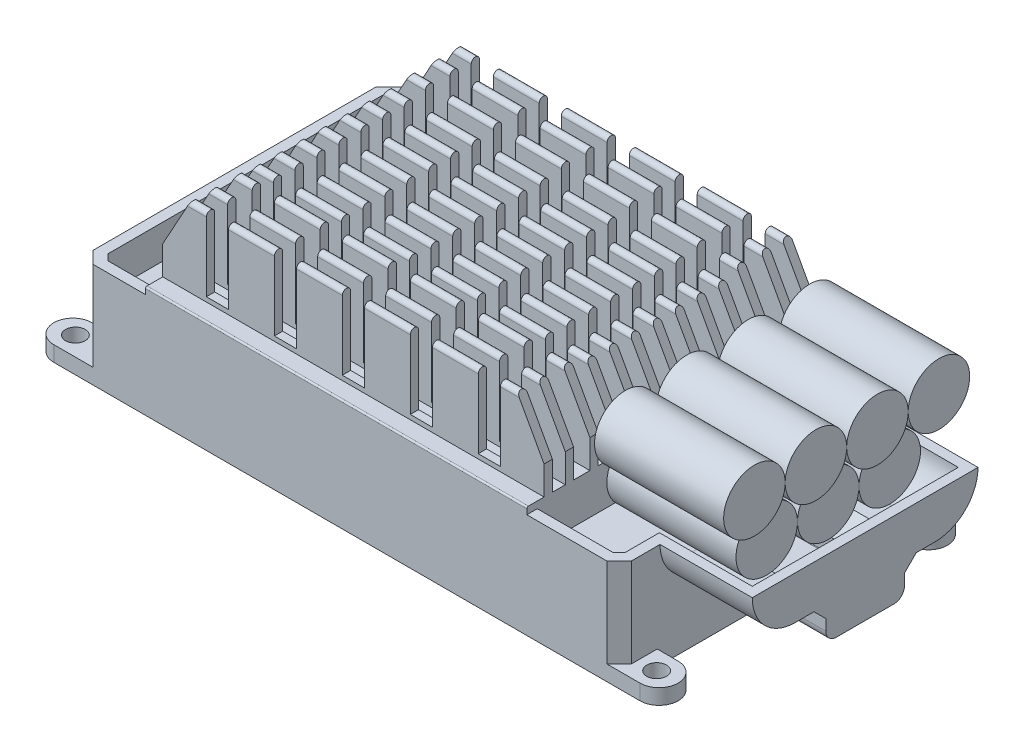
from build123d import *

# Parameters (mm, degrees)
SKETCH1_W               = 87.5
SKETCH1_H               = 50
BOSS_EXTRUDE1_DEPTH     = 17
SKETCH2_R               = 1.6
BOSS_EXTRUDE2_DEPTH     = 2.5
CHAMFER1_SIZE           = 2
BOSS_EXTRUDE3_DEPTH     = 62
SKETCH4_W               = 3.6
SKETCH4_H               = 11.9
CUT_EXTRUDE1_DEPTH      = 3.8
CUT_EXTRUDE1_DEPTH_BACK = 48.2
BOSS_EXTRUDE4_DEPTH     = 15
CUT_EXTRUDE3_DEPTH      = 5.5
CUT_EXTRUDE2_START      = -1.6
CUT_EXTRUDE2_DEPTH      = 15.1
BOSS_EXTRUDE5_START     = -3
SKETCH6_R               = 5
BOSS_EXTRUDE5_DEPTH     = 21
LPATTERN1_COUNT         = 4
LPATTERN1_PITCH         = 10
BOSS_EXTRUDE6_START     = -6
SKETCH7_R               = 4.9995
BOSS_EXTRUDE6_DEPTH     = 21
BOSS_EXTRUDE6_2_DEPTH   = 21
BOSS_EXTRUDE6_3_DEPTH   = 21


with BuildPart() as part:
    # Sketch1 → Boss-Extrude1 (new body)
    with BuildSketch(Plane(origin=(0, 0, 0), x_dir=(1, 0, 0), z_dir=(0, 1, 0))):
        Rectangle(SKETCH1_W, SKETCH1_H)
    extrude(amount=BOSS_EXTRUDE1_DEPTH)

    # Sketch2 → Boss-Extrude2 (add)
    with BuildSketch(Plane.XZ):
        with BuildLine():
            Line((43.75, 25), (47.15, 25))
            ThreePointArc((47.15, 25), (50.25, 21.9), (47.15, 18.8))
            Line((47.15, 18.8), (43.75, 18.8))
            Line((43.75, 18.8), (43.75, 25))
        make_face()
        with Locations((46.75, 21.9)):
            Circle(SKETCH2_R, mode=Mode.SUBTRACT)
        with BuildLine():
            Line((-43.75, 25), (-48.15, 25))
            ThreePointArc((-48.15, 25), (-51.25, 21.9), (-48.15, 18.8))
            Line((-48.15, 18.8), (-43.75, 18.8))
            Line((-43.75, 18.8), (-43.75, 25))
        make_face()
        with Locations((-47.75, 21.9)):
            Circle(SKETCH2_R, mode=Mode.SUBTRACT)
    boss_extrude2 = extrude(amount=-BOSS_EXTRUDE2_DEPTH)

    # Mirror5: Boss-Extrude2 across plane
    add(boss_extrude2.mirror(Plane.XY))

    # Chamfer1
    chamfer1_edges = [part.edges().sort_by_distance(p)[0] for p in [
        (-43.75, 9.75, 25),
        (-43.75, 9.75, -25),
        (43.75, 9.75, -25),
        (43.75, 9.75, 25),
    ]]
    chamfer(chamfer1_edges, length=CHAMFER1_SIZE)

    # Sketch3 → Boss-Extrude3 (add)
    with BuildSketch(Plane.ZY.offset(33.25)):
        with BuildLine():
            Line((-25, 17), (0, 17))
            Line((0, 17), (0, 30.1))
            ThreePointArc((0, 30.1), (-0.477297077, 29.902297077), (-0.675, 29.425))
            Line((-0.675, 29.425), (-0.675, 18.1))
            Line((-0.675, 18.1), (-2.9, 18.1))
            Line((-2.9, 18.1), (-2.9, 29.425))
            ThreePointArc((-2.9, 29.425), (-3.575, 30.1), (-4.25, 29.425))
            Line((-4.25, 29.425), (-4.25, 18.1))
            Line((-4.25, 18.1), (-6.45, 18.1))
            Line((-6.45, 18.1), (-6.45, 29.425))
            ThreePointArc((-6.45, 29.425), (-7.125, 30.1), (-7.8, 29.425))
            Line((-7.8, 29.425), (-7.8, 18.1))
            Line((-7.8, 18.1), (-9.95, 18.1))
            Line((-9.95, 18.1), (-9.95, 29.425))
            ThreePointArc((-9.95, 29.425), (-10.625, 30.1), (-11.3, 29.425))
            Line((-11.3, 29.425), (-11.3, 18.1))
            Line((-11.3, 18.1), (-13.4, 18.1))
            Line((-13.4, 18.1), (-13.4, 30.075))
            ThreePointArc((-13.4, 30.075), (-14.075, 30.75), (-14.75, 30.075))
            Line((-14.75, 30.075), (-14.75, 18.1))
            Line((-14.75, 18.1), (-17.4, 18.1))
            Line((-17.4, 18.1), (-17.4, 30.075))
            ThreePointArc((-17.4, 30.075), (-18.075, 30.75), (-18.75, 30.075))
            Line((-18.75, 30.075), (-18.75, 18.1))
            Line((-18.75, 18.1), (-20.85, 18.1))
            Line((-20.85, 18.1), (-20.85, 30.075))
            ThreePointArc((-20.85, 30.075), (-21.525, 30.75), (-22.2, 30.075))
            Line((-22.2, 30.075), (-22.2, 18.1))
            Line((-22.2, 18.1), (-24.75, 18.1))
            ThreePointArc((-24.75, 18.1), (-24.926776695, 18.026776695), (-25, 17.85))
            Line((-25, 17.85), (-25, 17))
        make_face()
    boss_extrude3 = extrude(amount=-BOSS_EXTRUDE3_DEPTH)

    # Mirror3: Boss-Extrude3 across plane
    add(boss_extrude3.mirror(Plane.XY))

    # Sketch4 → Cut-Extrude1 (cut, two sides)
    with BuildSketch(Plane(origin=(0, 0, -22.2), x_dir=(-1, 0, 0), z_dir=(0, 0, -1))) as cut_extrude1_sk:
        Polygon((28.85, 30.75), (33.25, 22.75), (33.25, 30.75), align=None)
        Polygon((-28.75, 22.75), (-24.35, 30.75), (-28.75, 30.75), align=None)
        with Locations((-19.85, 24.8)):
            Rectangle(SKETCH4_W, SKETCH4_H)
        with Locations((-8.8, 24.8)):
            Rectangle(SKETCH4_W, SKETCH4_H)
        with Locations((2.25, 24.8)):
            Rectangle(SKETCH4_W, SKETCH4_H)
        with Locations((13.3, 24.8)):
            Rectangle(SKETCH4_W, SKETCH4_H)
        with Locations((24.35, 24.8)):
            Rectangle(SKETCH4_W, SKETCH4_H)
    extrude(amount=CUT_EXTRUDE1_DEPTH, mode=Mode.SUBTRACT)
    extrude(cut_extrude1_sk.sketch, amount=-CUT_EXTRUDE1_DEPTH_BACK, mode=Mode.SUBTRACT)

    # Sketch5 → Boss-Extrude4 (add)
    with BuildSketch(Plane(origin=(43.75, 0, 0), x_dir=(0, 0, -1), z_dir=(1, 0, 0))):
        with BuildLine():
            Line((0, 4.6), (0, 17))
            Line((0, 17), (-18.35, 17))
            ThreePointArc((-18.35, 17), (-16.299747468, 12.050252532), (-11.35, 10))
            Line((-11.35, 10), (-8.309188309, 10))
            Line((-8.309188309, 10), (-6.4, 8.090811691))
            Line((-6.4, 8.090811691), (-6.4, 6.3))
            ThreePointArc((-6.4, 6.3), (-5.902081528, 5.097918472), (-4.7, 4.6))
            Line((-4.7, 4.6), (0, 4.6))
        make_face()
    boss_extrude4 = extrude(amount=BOSS_EXTRUDE4_DEPTH)

    # Mirror4: Boss-Extrude4 across plane
    add(boss_extrude4.mirror(Plane.XY))

    # Sketch9 → Cut-Extrude3 (cut)
    with BuildSketch(Plane(origin=(0, 17, 0), x_dir=(1, 0, 0), z_dir=(0, 1, 0))):
        Polygon((28.75, -23.3), (28.75, 23.3), (41.045836944, 23.3), (42.05, 22.295836944), (42.05, 18.35), (42.05, -18.35), (42.05, -22.295836944), (41.045836944, -23.3), align=None)
        Polygon((-33.25, 23.3), (-33.25, -23.3), (-41.045836944, -23.3), (-42.05, -22.295836944), (-42.05, 22.295836944), (-41.045836944, 23.3), align=None)
    extrude(amount=-CUT_EXTRUDE3_DEPTH, mode=Mode.SUBTRACT)

    # Sketch8 → Cut-Extrude2 (cut)
    with BuildSketch(Plane(origin=(58.75, 0, 0), x_dir=(0, 0, -1), z_dir=(1, 0, 0)).offset(CUT_EXTRUDE2_START)):
        with BuildLine():
            Line((-16.75, 17), (16.75, 17))
            ThreePointArc((16.75, 17), (15.168376618, 13.181623382), (11.35, 11.6))
            Line((11.35, 11.6), (7.646446609, 11.6))
            Line((7.646446609, 11.6), (4.8, 8.753553391))
            Line((4.8, 8.753553391), (4.8, 6.3))
            ThreePointArc((4.8, 6.3), (4.770710678, 6.229289322), (4.7, 6.2))
            Line((4.7, 6.2), (-4.7, 6.2))
            ThreePointArc((-4.7, 6.2), (-4.770710678, 6.229289322), (-4.8, 6.3))
            Line((-4.8, 6.3), (-4.8, 8.753553391))
            Line((-4.8, 8.753553391), (-7.646446609, 11.6))
            Line((-7.646446609, 11.6), (-11.35, 11.6))
            ThreePointArc((-11.35, 11.6), (-15.168376618, 13.181623382), (-16.75, 17))
        make_face()
    extrude(amount=-CUT_EXTRUDE2_DEPTH, mode=Mode.SUBTRACT)


with BuildPart() as body_2:
    # Sketch6 → Boss-Extrude5 (new body)
    with BuildSketch(Plane(origin=(58.75, 0, 0), x_dir=(0, 0, -1), z_dir=(1, 0, 0)).offset(BOSS_EXTRUDE5_START)):
        with Locations((-15, 27.5)):
            Circle(SKETCH6_R)
    boss_extrude5 = extrude(amount=-BOSS_EXTRUDE5_DEPTH)


with BuildPart() as lpattern1_1:
    # LPattern1: Boss-Extrude5 ×4
    with Locations(*[(0, 0, -i * LPATTERN1_PITCH) for i in range(1, LPATTERN1_COUNT)]):
        add(boss_extrude5)


with BuildPart() as body_6:
    # Sketch7 → Boss-Extrude6 (new body)
    with BuildSketch(Plane(origin=(58.75, 0, 0), x_dir=(0, 0, -1), z_dir=(1, 0, 0)).offset(BOSS_EXTRUDE6_START)):
        with Locations((-10, 18)):
            Circle(SKETCH7_R)
    extrude(amount=-BOSS_EXTRUDE6_DEPTH)


with BuildPart() as body_7:
    # Sketch7 → Boss-Extrude6 2 (new body)
    with BuildSketch(Plane(origin=(58.75, 0, 0), x_dir=(0, 0, -1), z_dir=(1, 0, 0)).offset(BOSS_EXTRUDE6_START)):
        with Locations((0, 18)):
            Circle(SKETCH7_R)
    extrude(amount=-BOSS_EXTRUDE6_2_DEPTH)


with BuildPart() as body_8:
    # Sketch7 → Boss-Extrude6 3 (new body)
    with BuildSketch(Plane(origin=(58.75, 0, 0), x_dir=(0, 0, -1), z_dir=(1, 0, 0)).offset(BOSS_EXTRUDE6_START)):
        with Locations((10, 18)):
            Circle(SKETCH7_R)
    extrude(amount=-BOSS_EXTRUDE6_3_DEPTH)


solid = Compound([part.part, body_2.part, lpattern1_1.part, body_6.part, body_7.part, body_8.part])
